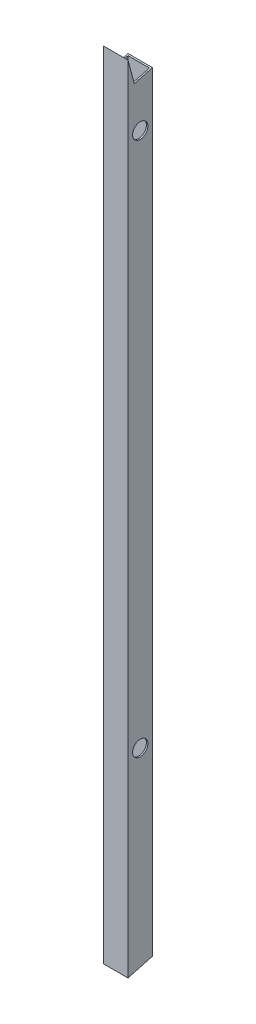
from build123d import *

# Parameters (mm, degrees)
SKETCH1_W               = 25.4
SKETCH1_H               = 25.4
SKETCH1_W_2             = 22.352
SKETCH1_H_2             = 22.352
BOSS_EXTRUDE1_DEPTH     = 883.666
SKETCH5_R               = 7.9375
CUT_EXTRUDE3_DEPTH      = 1
CUT_EXTRUDE3_DEPTH_BACK = 26.4
SKETCH6_R               = 7.9375
CUT_EXTRUDE4_DEPTH      = 1
CUT_EXTRUDE4_DEPTH_BACK = 26.4
CUT_EXTRUDE5_DEPTH      = 1
CUT_EXTRUDE5_DEPTH_BACK = 26.4
CUT_EXTRUDE6_DEPTH      = 1
CUT_EXTRUDE6_DEPTH_BACK = 26.4


with BuildPart() as part:
    # Sketch1 → Boss-Extrude1 (new body)
    with BuildSketch(Plane(origin=(0, 0, 0), x_dir=(1, 0, 0), z_dir=(0, 1, 0))):
        with Locations((-46.655111286, 37.676591231)):
            Rectangle(SKETCH1_W, SKETCH1_H)
        with Locations((-46.655111286, 37.676591231)):
            Rectangle(SKETCH1_W_2, SKETCH1_H_2, mode=Mode.SUBTRACT)
    extrude(amount=BOSS_EXTRUDE1_DEPTH)

    # Sketch5 → Cut-Extrude3 (cut, two sides)
    with BuildSketch(Plane(origin=(-33.955111286, 0, 0), x_dir=(0, 0, -1), z_dir=(1, 0, 0))) as cut_extrude3_sk:
        with Locations((37.676591231, 258.318)):
            Circle(SKETCH5_R)
    extrude(amount=CUT_EXTRUDE3_DEPTH, mode=Mode.SUBTRACT)
    extrude(cut_extrude3_sk.sketch, amount=-CUT_EXTRUDE3_DEPTH_BACK, mode=Mode.SUBTRACT)

    # Sketch6 → Cut-Extrude4 (cut, two sides)
    with BuildSketch(Plane(origin=(-33.955111286, 0, 0), x_dir=(0, 0, -1), z_dir=(1, 0, 0))) as cut_extrude4_sk:
        with Locations((37.676591231, 813.943)):
            Circle(SKETCH6_R)
    extrude(amount=CUT_EXTRUDE4_DEPTH, mode=Mode.SUBTRACT)
    extrude(cut_extrude4_sk.sketch, amount=-CUT_EXTRUDE4_DEPTH_BACK, mode=Mode.SUBTRACT)

    # Sketch7 → Cut-Extrude5 (cut, two sides)
    with BuildSketch(Plane(origin=(-33.955111286, 0, 0), x_dir=(0, 0, -1), z_dir=(1, 0, 0))) as cut_extrude5_sk:
        Polygon((24.976591231, 883.666), (31.52840716, 859.214290072), (50.376591231, 864.264645773), (50.376591231, 883.666), align=None)
    extrude(amount=CUT_EXTRUDE5_DEPTH, mode=Mode.SUBTRACT)
    extrude(cut_extrude5_sk.sketch, amount=-CUT_EXTRUDE5_DEPTH_BACK, mode=Mode.SUBTRACT)

    # Sketch8 → Cut-Extrude6 (cut, two sides)
    with BuildSketch(Plane(origin=(-33.955111286, 0, 0), x_dir=(0, 0, -1), z_dir=(1, 0, 0))) as cut_extrude6_sk:
        Polygon((24.976591231, 57.658), (24.976591231, 0), (50.376591231, 0), (50.376591231, 64.516), align=None)
    extrude(amount=CUT_EXTRUDE6_DEPTH, mode=Mode.SUBTRACT)
    extrude(cut_extrude6_sk.sketch, amount=-CUT_EXTRUDE6_DEPTH_BACK, mode=Mode.SUBTRACT)


solid = part.part
